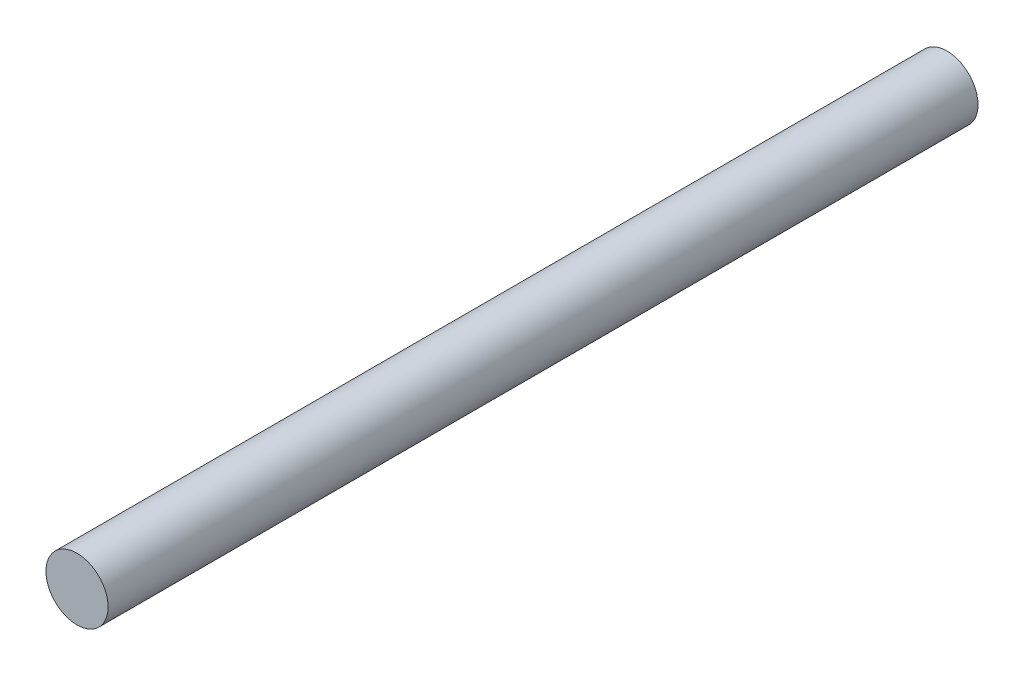
from build123d import *

# Parameters (mm, degrees)
SKETCH1_R           = 1.5875
BOSS_EXTRUDE1_DEPTH = 44.45


with BuildPart() as part:
    # Sketch1 → Boss-Extrude1 (new body)
    with BuildSketch(Plane.XY):
        Circle(SKETCH1_R)
    extrude(amount=BOSS_EXTRUDE1_DEPTH)


solid = part.part
